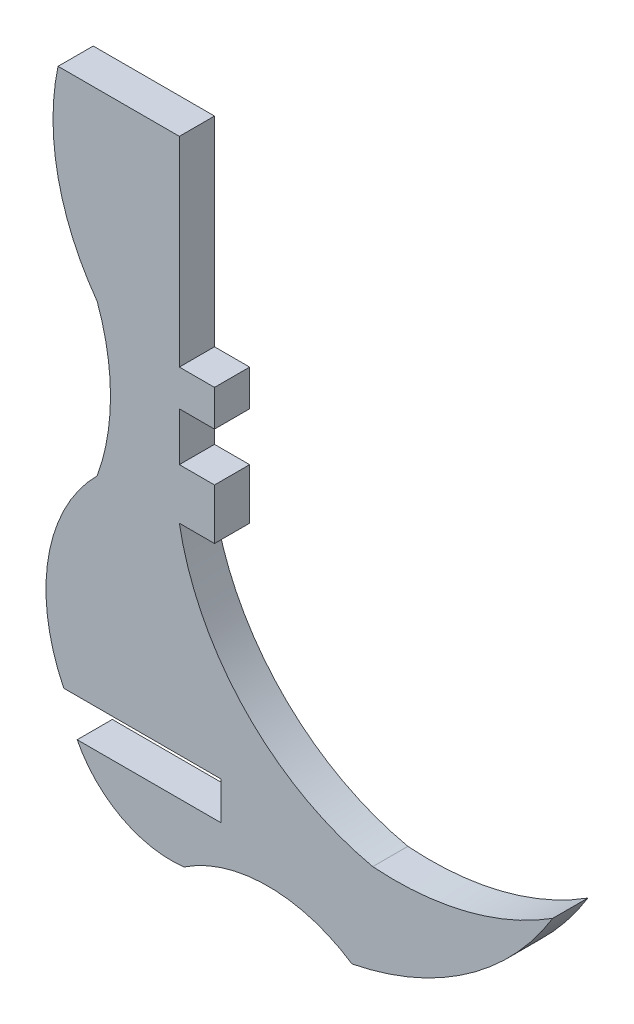
from build123d import *

# Parameters (mm, degrees)
BOSS_EXTRUDE1_DEPTH = 1.524


with BuildPart() as part:
    # Sketch1 → Boss-Extrude1 (new body)
    with BuildSketch(Plane.XY):
        with BuildLine():
            Line((0, -1.964327556), (-1.524, -1.964327556))
            Line((-1.524, -1.964327556), (-1.524, 0.132092651))
            Line((-1.524, 0.132092651), (0, 0.132092651))
            Line((0, 0.132092651), (0, 1.699735594))
            Line((0, 1.699735594), (-1.524, 1.699735594))
            Line((-1.524, 1.699735594), (-1.524, 7.30837055))
            Line((-1.524, 7.30837055), (-1.524, 10.365124178))
            Line((-1.524, 10.365124178), (-6.782878703, 10.365124178))
            ThreePointArc((-6.782878703, 10.365124178), (-6.783116279, 6.194251187), (-5.086577691, 2.384009936))
            ThreePointArc((-5.086577691, 2.384009936), (-4.509773665, -0.889665066), (-5.086577691, -4.163340068))
            ThreePointArc((-5.086577691, -4.163340068), (-7.205112449, -8.282791607), (-6.536296983, -12.866540768))
            Line((-6.536296983, -12.866540768), (0.285426682, -12.866540768))
            Line((0.285426682, -12.866540768), (0.285426682, -14.508842733))
            Line((0.285426682, -14.508842733), (-5.954978709, -14.508842733))
            ThreePointArc((-5.954978709, -14.508842733), (-4.027344351, -16.471916174), (-1.321752383, -16.971119191))
            ThreePointArc((-1.321752383, -16.971119191), (2.319118957, -15.86929322), (5.959990297, -16.971119191))
            ThreePointArc((5.959990297, -16.971119191), (10.949556437, -14.851489508), (14.666489015, -10.905223871))
            ThreePointArc((14.666489015, -10.905223871), (10.922843112, -12.5189914), (6.861028282, -12.866540768))
            ThreePointArc((6.861028282, -12.866540768), (1.349866502, -9.785380814), (-1.524, -4.163340068))
            Line((-1.524, -4.163340068), (0, -4.163340068))
            Line((0, -4.163340068), (0, -1.964327556))
        make_face()
    extrude(amount=BOSS_EXTRUDE1_DEPTH)


solid = part.part
